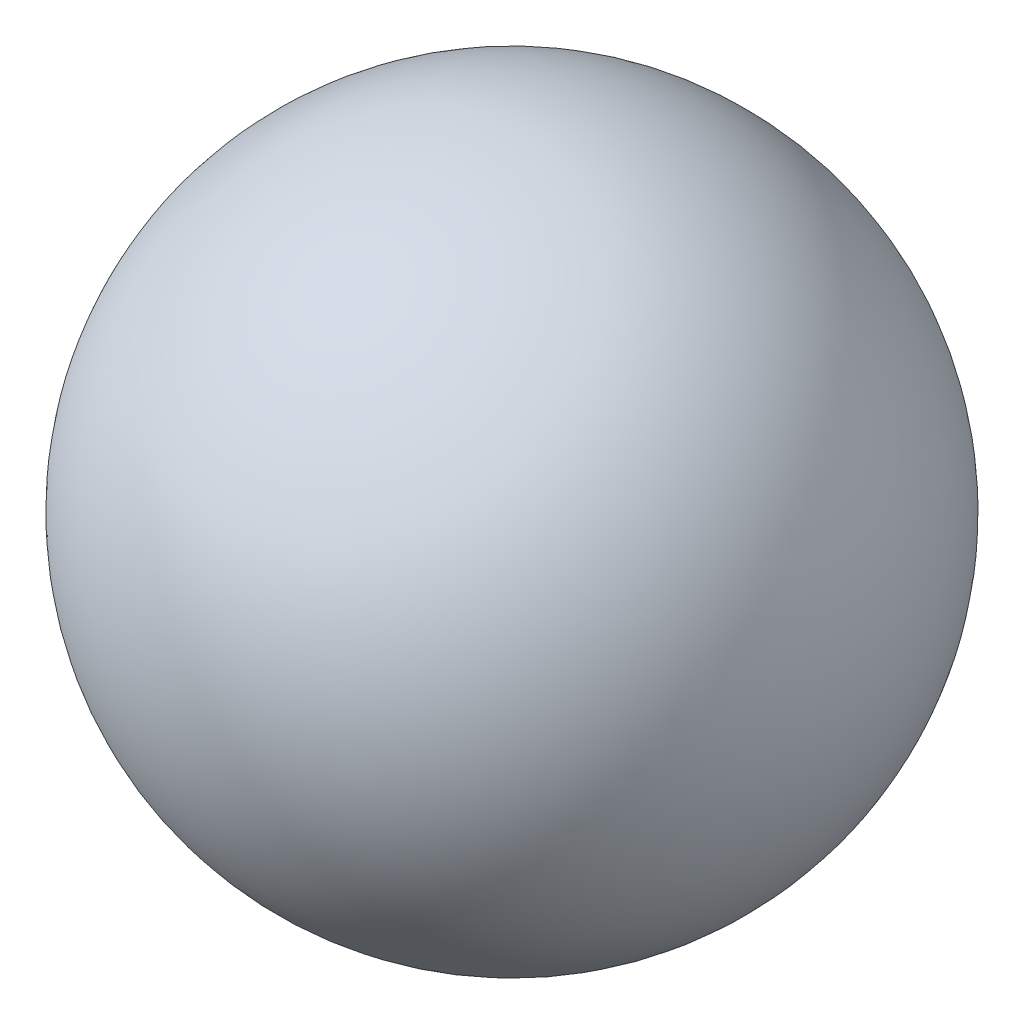
from build123d import *


with BuildPart() as part:
    # 草圖1 one side → 旋轉1 (revolve)
    with BuildSketch(Plane.XY):
        with BuildLine():
            Line((-7.5, 0), (7.5, 0))
            ThreePointArc((7.5, 0), (0, 7.5), (-7.5, 0))
        make_face()
    revolve(axis=Axis((-7.5, 0, 0), (1, 0, 0)))


solid = part.part
